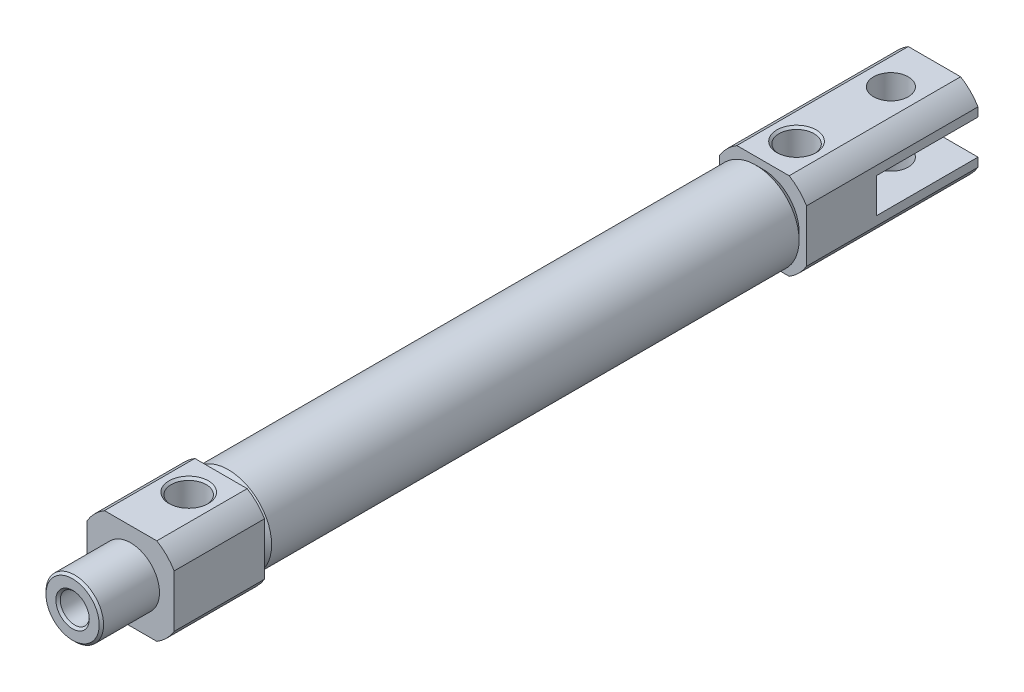
from build123d import *

# Parameters (mm, degrees)
SKETCH1_R                  = 5.97
BASE_EXTRUDE_DEPTH         = 37.335
BASE_EXTRUDE_DEPTH_BACK    = 37.335
TUBECHAMFER_SIZE           = 1
RODCOVER_DEPTH             = 12.45
HEADCOVER_DEPTH            = 23.62
SKETCH4_R                  = 3.96875
NOSETHREADS_DEPTH          = 8
SKETCH5_R                  = 2.415
FRONTPORT_DEPTH            = 7
RODBORE_START              = -85.685
SKETCH10_R                 = 2
RODBORE_DEPTH              = 85.685
SKETCH11_R                 = 5
STROKECHAMBER_DEPTH        = 55.8
SKETCH13_W                 = 13.97
SKETCH13_H                 = 4.78
D_CLEVISSIDECUT_DEPTH      = 7
D_CLEVISSIDECUT_DEPTH_BACK = 7
DETAILCHAMFER_SIZE         = 0.3
SKETCH12_R                 = 2.39
CUT_EXTRUDE1_DEPTH         = 7
CUT_EXTRUDE1_DEPTH_BACK    = 7


with BuildPart() as part:
    # Sketch1 → Base-Extrude (new body, two sides)
    with BuildSketch(Plane.XY) as base_extrude_sk:
        Circle(SKETCH1_R)
    extrude(amount=BASE_EXTRUDE_DEPTH)
    extrude(base_extrude_sk.sketch, amount=-BASE_EXTRUDE_DEPTH_BACK)

    # TubeChamfer
    tubechamfer_edges = [part.edges().sort_by_distance(p)[0] for p in [
        (-5.97, 0, -37.335),
        (-5.97, 0, 37.335),
    ]]
    chamfer(tubechamfer_edges, length=TUBECHAMFER_SIZE)

    # Sketch2 → RodCover (add)
    with BuildSketch(Plane.XY.offset(37.335)):
        with BuildLine():
            Line((-3.605551275, 6), (3.605551275, 6))
            ThreePointArc((3.605551275, 6), (4.949747468, 4.949747468), (6, 3.605551275))
            Line((6, 3.605551275), (6, -3.605551275))
            ThreePointArc((6, -3.605551275), (4.949747468, -4.949747468), (3.605551275, -6))
            Line((3.605551275, -6), (-3.605551275, -6))
            ThreePointArc((-3.605551275, -6), (-4.949747468, -4.949747468), (-6, -3.605551275))
            Line((-6, -3.605551275), (-6, 3.605551275))
            ThreePointArc((-6, 3.605551275), (-4.949747468, 4.949747468), (-3.605551275, 6))
        make_face()
    extrude(amount=RODCOVER_DEPTH)

    # Sketch3 → HeadCover (add)
    with BuildSketch(Plane(origin=(0, 0, -37.335), x_dir=(-1, 0, 0), z_dir=(0, 0, -1))):
        with BuildLine():
            Line((-3.605551275, 6), (3.605551275, 6))
            ThreePointArc((3.605551275, 6), (4.949747468, 4.949747468), (6, 3.605551275))
            Line((6, 3.605551275), (6, -3.605551275))
            ThreePointArc((6, -3.605551275), (4.949747468, -4.949747468), (3.605551275, -6))
            Line((3.605551275, -6), (-3.605551275, -6))
            ThreePointArc((-3.605551275, -6), (-4.949747468, -4.949747468), (-6, -3.605551275))
            Line((-6, -3.605551275), (-6, 3.605551275))
            ThreePointArc((-6, 3.605551275), (-4.949747468, 4.949747468), (-3.605551275, 6))
        make_face()
    extrude(amount=HEADCOVER_DEPTH)

    # Sketch4 → NoseThreads (add)
    with BuildSketch(Plane.XY.offset(49.785)):
        Circle(SKETCH4_R)
    extrude(amount=NOSETHREADS_DEPTH)

    # Sketch5 → FrontPort (cut, through all)
    with BuildSketch(Plane(origin=(0, 0, 0), x_dir=(1, 0, 0), z_dir=(0, 1, 0))):
        with Locations((0, -41.785)):
            Circle(SKETCH5_R)
    extrude(amount=FRONTPORT_DEPTH, mode=Mode.SUBTRACT)

    # Sketch7 → RearTopPort (revolve, cut)
    with BuildSketch(Plane(origin=(0, 0, 0), x_dir=(0, 0, -1), z_dir=(1, 0, 0))):
        Polygon((41.955, 0), (44.37, 0), (44.37, 5.7), (44.67, 6), (41.955, 6), align=None)
    revolve(axis=Axis((0, 0, -41.955), (0, 1, 0)), mode=Mode.SUBTRACT)

    # Sketch10 → RodBore (cut)
    with BuildSketch(Plane.XY.offset(57.785).offset(RODBORE_START)):
        Circle(SKETCH10_R)
    extrude(amount=RODBORE_DEPTH, mode=Mode.SUBTRACT)

    # Sketch11 → StrokeChamber (cut)
    with BuildSketch(Plane.XY.offset(-27.9)):
        Circle(SKETCH11_R)
    extrude(amount=STROKECHAMBER_DEPTH, mode=Mode.SUBTRACT)

    # Sketch13 → D-ClevisSideCut (cut, two sides)
    with BuildSketch(Plane(origin=(0, 0, 0), x_dir=(0, 0, -1), z_dir=(1, 0, 0))) as d_clevissidecut_sk:
        with Locations((53.97, 0)):
            Rectangle(SKETCH13_W, SKETCH13_H)
    extrude(amount=D_CLEVISSIDECUT_DEPTH, mode=Mode.SUBTRACT)
    extrude(d_clevissidecut_sk.sketch, amount=-D_CLEVISSIDECUT_DEPTH_BACK, mode=Mode.SUBTRACT)

    # DetailChamfer
    detailchamfer_edges = [part.edges().sort_by_distance(p)[0] for p in [
        (-3.96875, 0, 57.785),
        (-2.415, 6, 41.785),
        (-2, 0, 57.785),
    ]]
    chamfer(detailchamfer_edges, length=DETAILCHAMFER_SIZE)

    # Sketch12 → Cut-Extrude1 (cut, two sides)
    with BuildSketch(Plane(origin=(0, 0, 0), x_dir=(1, 0, 0), z_dir=(0, 1, 0))) as cut_extrude1_sk:
        with Locations((0, 54.955)):
            Circle(SKETCH12_R)
    extrude(amount=CUT_EXTRUDE1_DEPTH, mode=Mode.SUBTRACT)
    extrude(cut_extrude1_sk.sketch, amount=-CUT_EXTRUDE1_DEPTH_BACK, mode=Mode.SUBTRACT)


solid = part.part
